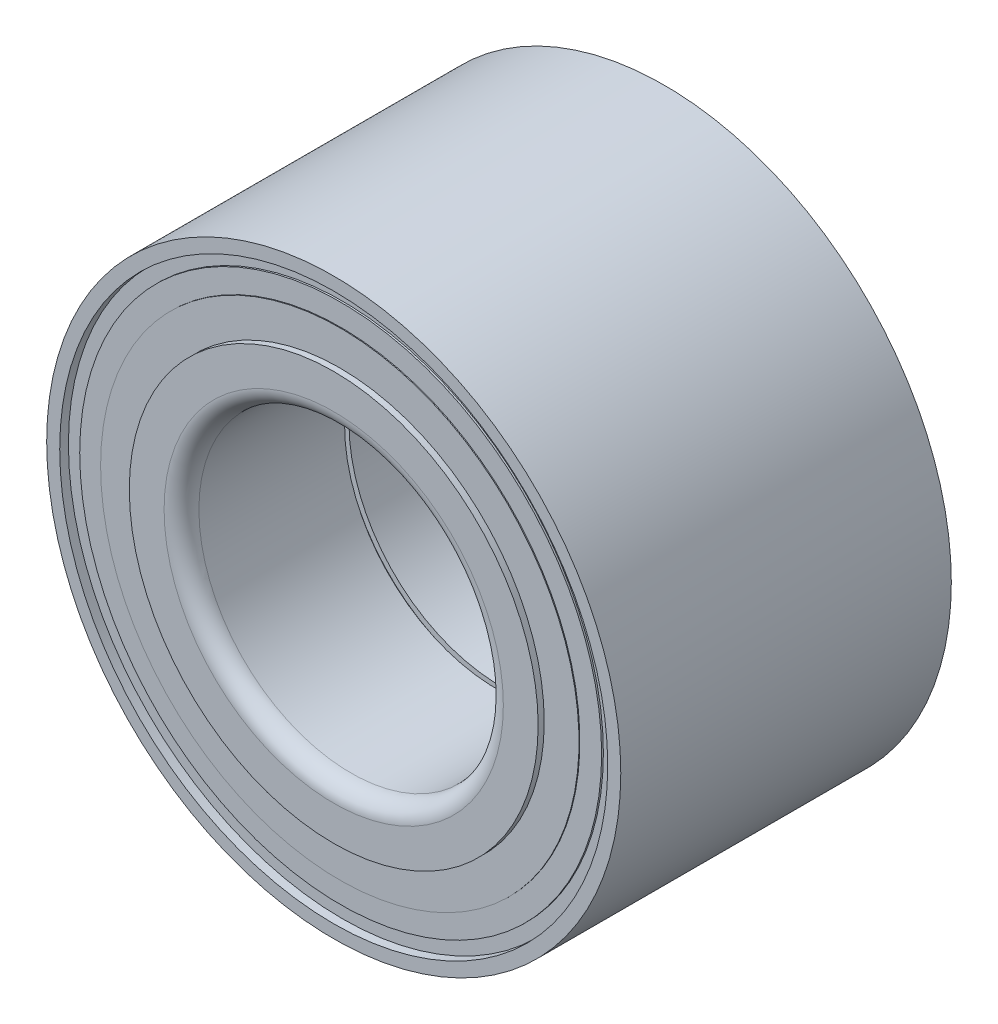
from build123d import *

# Parameters (mm, degrees)
CROQUIS1_R              = 33
CROQUIS1_R_2            = 17.5
SALIENTE_EXTRUIR1_DEPTH = 19
REDONDEO1_R             = 2
REDONDEO2_R             = 2


with BuildPart() as part:
    # Croquis1 → Saliente-Extruir1 (new body, symmetric)
    with BuildSketch(Plane.XY):
        Circle(CROQUIS1_R)
        Circle(CROQUIS1_R_2, mode=Mode.SUBTRACT)
    extrude(amount=SALIENTE_EXTRUIR1_DEPTH, both=True)

    # Croquis2 → Cortar-Revolución1 (revolve, cut)
    with BuildSketch(Plane(origin=(0, 0, 0), x_dir=(1, 0, 0), z_dir=(0, 1, 0))):
        with BuildLine():
            Line((17.75, 0.5), (18.5, 0.5))
            Line((18.5, 0.5), (18.5, -0.5))
            Line((18.5, -0.5), (17.75, -0.5))
            ThreePointArc((17.75, -0.5), (17.573223305, -0.426776695), (17.5, -0.25))
            Line((17.5, -0.25), (17.5, 0.25))
            ThreePointArc((17.5, 0.25), (17.573223305, 0.426776695), (17.75, 0.5))
        make_face()
    revolve(axis=Axis((0, 0, 0), (0, 0, -1)), mode=Mode.SUBTRACT)

    # Redondeo1
    redondeo1_edges = [part.edges().sort_by_distance(p)[0] for p in [
        (-17.5, 0, 19),
    ]]
    fillet(redondeo1_edges, radius=REDONDEO1_R)

    # Croquis3 → Cortar-Revolución2 (revolve, cut)
    with BuildSketch(Plane(origin=(0, 0, 0), x_dir=(0, 0, -1), z_dir=(1, 0, 0))):
        Polygon((-19, 23.5), (-19, 31.5), (-18, 31.5), (-18, 30), (-18.2, 30), (-18.2, 27.5), (-18.3, 27.5), (-18.3, 23.5), align=None)
    cortar_revoluci_n2 = revolve(axis=Axis((0, 0, 0), (0, 0, 1)), mode=Mode.SUBTRACT)

    # Redondeo2
    redondeo2_edges = [part.edges().sort_by_distance(p)[0] for p in [
        (-17.5, 0, -19),
    ]]
    fillet(redondeo2_edges, radius=REDONDEO2_R)

    # Simetría1: Cortar-Revolución2 across plane
    add(cortar_revoluci_n2.mirror(Plane.XY), mode=Mode.SUBTRACT)


solid = part.part
